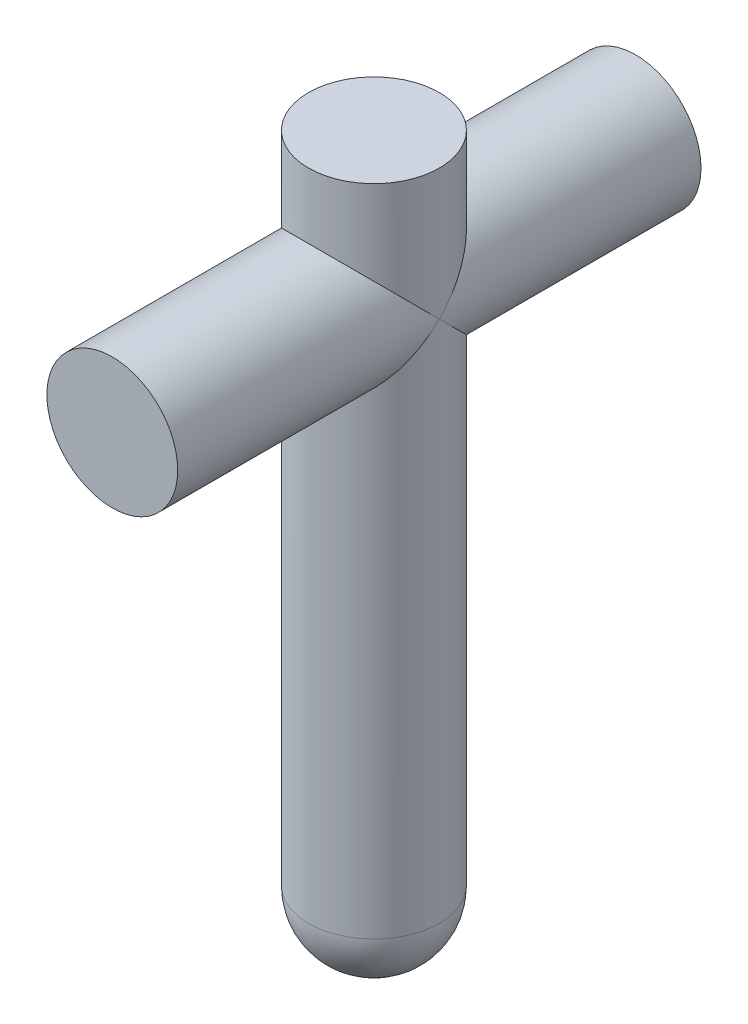
from build123d import *

# Parameters (mm, degrees)
SKETCH1_R           = 3.175
BOSS_EXTRUDE1_DEPTH = 31.75
SKETCH2_R           = 3.175
BOSS_EXTRUDE2_DEPTH = 12.7
DOME2_FACE_RADIUS   = 3.175
DOME2_HEIGHT        = 3.175


with BuildPart() as part:
    # Sketch1 → Boss-Extrude1 (new body)
    with BuildSketch(Plane(origin=(0, 0, 0), x_dir=(1, 0, 0), z_dir=(0, 1, 0))):
        Circle(SKETCH1_R)
    extrude(amount=BOSS_EXTRUDE1_DEPTH)

    # Sketch2 → Boss-Extrude2 (add, symmetric)
    with BuildSketch(Plane.XY):
        with Locations((0, 25.4)):
            Circle(SKETCH2_R)
    extrude(amount=BOSS_EXTRUDE2_DEPTH, both=True)

    # Dome2: a dome of height H over a round flat face of radius A is a cap of a sphere of radius (A * A + H * H) / (2 * H)
    dome2_r = (DOME2_FACE_RADIUS * DOME2_FACE_RADIUS + DOME2_HEIGHT * DOME2_HEIGHT) / (2 * DOME2_HEIGHT)
    dome2_base = Plane((0, 0, 0), z_dir=(0, -1, 0))
    with Locations(dome2_base.offset(DOME2_HEIGHT - dome2_r)):
        dome2_ball = Sphere(dome2_r, mode=Mode.PRIVATE)
    add(split(dome2_ball, bisect_by=dome2_base, keep=Keep.TOP, mode=Mode.PRIVATE))


solid = part.part
